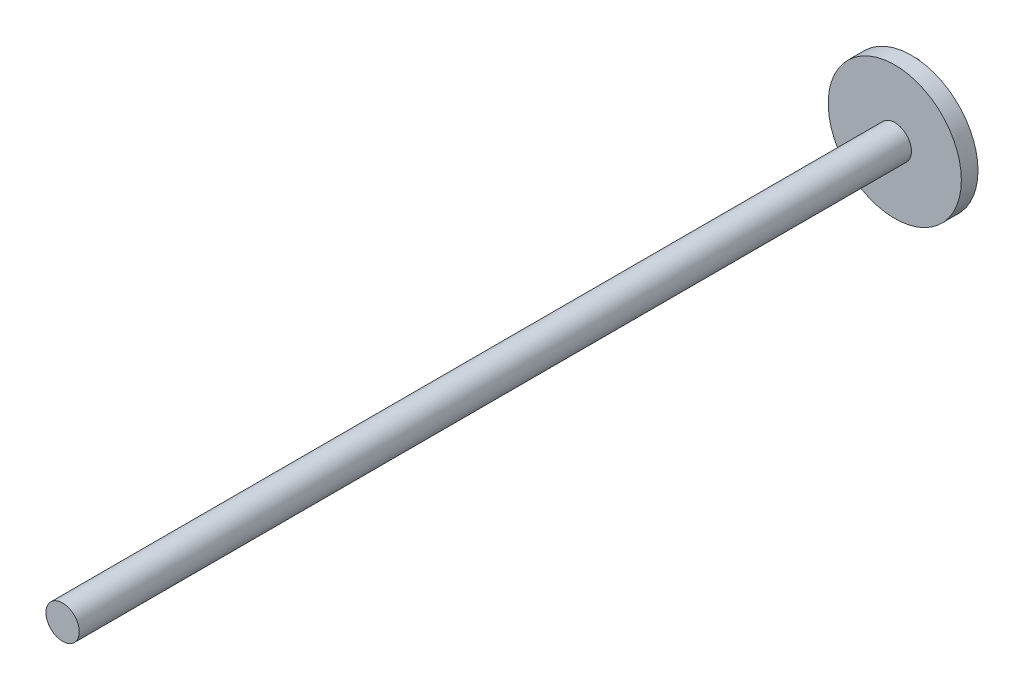
from build123d import *

# Parameters (mm, degrees)
SKETCH1_R           = 40
BOSS_EXTRUDE1_DEPTH = 10
SKETCH2_R           = 10
BOSS_EXTRUDE2_DEPTH = 500
SKETCH3_R           = 10
BOSS_EXTRUDE3_DEPTH = 30


with BuildPart() as part:
    # Sketch1 → Boss-Extrude1 (new body)
    with BuildSketch(Plane.XY):
        Circle(SKETCH1_R)
    extrude(amount=BOSS_EXTRUDE1_DEPTH)

    # Sketch2 → Boss-Extrude2 (add)
    with BuildSketch(Plane.XY.offset(10)):
        Circle(SKETCH2_R)
    extrude(amount=BOSS_EXTRUDE2_DEPTH)

    # Sketch3 → Boss-Extrude3 (add)
    with BuildSketch(Plane(origin=(0, 0, 0), x_dir=(-1, 0, 0), z_dir=(0, 0, -1))):
        with Locations((26.998561916, 0)):
            Circle(SKETCH3_R)
    extrude(amount=BOSS_EXTRUDE3_DEPTH)


solid = part.part
